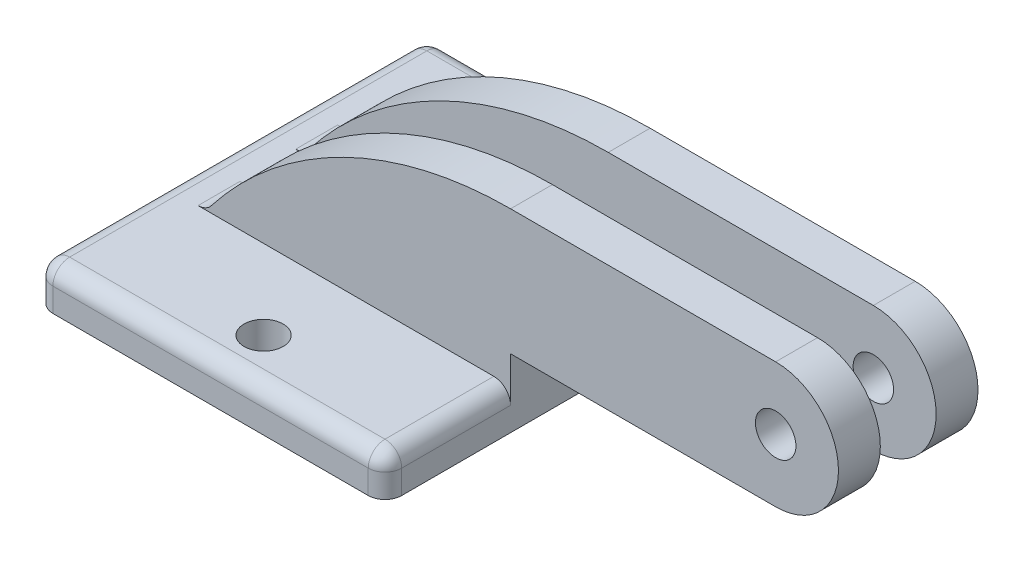
from build123d import *

# Parameters (mm, degrees)
SKETCH1_W           = 15.875
SKETCH1_H           = 17.78
SKETCH1_R           = 0.889
BOSS_EXTRUDE1_DEPTH = 1.8415
SKETCH2_R           = 0.92075
BOSS_EXTRUDE2_DEPTH = 3.175
SKETCH2_2_R         = 0.92075
CUT_EXTRUDE1_DEPTH  = 1.27
FILLET1_R           = 0.762


with BuildPart() as part:
    # Sketch1 → Boss-Extrude1 (new body)
    with BuildSketch(Plane(origin=(0, 0, 0), x_dir=(1, 0, 0), z_dir=(0, 1, 0))):
        Rectangle(SKETCH1_W, SKETCH1_H)
        with Locations((0.3175, 6.7945)):
            Circle(SKETCH1_R, mode=Mode.SUBTRACT)
        with Locations((0.3175, -6.7945)):
            Circle(SKETCH1_R, mode=Mode.SUBTRACT)
    extrude(amount=BOSS_EXTRUDE1_DEPTH)

    # Sketch2 → Boss-Extrude2 (add, symmetric)
    with BuildSketch(Plane.XY):
        with BuildLine():
            ThreePointArc((7.9375, 8.8265), (0.184776704, 6.981333441), (-5.9055, 1.8415))
            Line((-5.9055, 1.8415), (7.9375, 1.8415))
            Line((7.9375, 1.8415), (7.9375, 3.1115))
            Line((7.9375, 3.1115), (20.0025, 3.1115))
            ThreePointArc((20.0025, 3.1115), (22.86, 5.969), (20.0025, 8.8265))
            Line((20.0025, 8.8265), (7.9375, 8.8265))
        make_face()
        with Locations((20.0025, 5.969)):
            Circle(SKETCH2_R, mode=Mode.SUBTRACT)
    extrude(amount=BOSS_EXTRUDE2_DEPTH, both=True)

    # Sketch2_2 → Cut-Extrude1 (cut, symmetric)
    with BuildSketch(Plane.XY):
        with BuildLine():
            ThreePointArc((7.9375, 8.8265), (0.184776704, 6.981333441), (-5.9055, 1.8415))
            Line((-5.9055, 1.8415), (7.9375, 1.8415))
            Line((7.9375, 1.8415), (7.9375, 3.1115))
            Line((7.9375, 3.1115), (20.0025, 3.1115))
            ThreePointArc((20.0025, 3.1115), (22.86, 5.969), (20.0025, 8.8265))
            Line((20.0025, 8.8265), (7.9375, 8.8265))
        make_face()
        with Locations((20.0025, 5.969)):
            Circle(SKETCH2_2_R, mode=Mode.SUBTRACT)
    extrude(amount=CUT_EXTRUDE1_DEPTH, both=True, mode=Mode.SUBTRACT)

    # Fillet1
    fillet1_edges = [part.edges().sort_by_distance(p)[0] for p in [
        (7.9375, 0.92075, -8.89),
        (-7.9375, 0.92075, -8.89),
        (7.9375, 0.92075, 8.89),
        (-7.9375, 0.92075, 8.89),
        (-5.9055, 1.8415, -2.2225),
        (-5.9055, 1.8415, 2.2225),
        (7.9375, 1.8415, -6.0325),
        (0, 1.8415, -8.89),
        (0, 1.8415, 8.89),
        (7.9375, 1.8415, 6.0325),
        (-7.9375, 1.8415, 0),
    ]]
    fillet(fillet1_edges, radius=FILLET1_R)


solid = part.part
